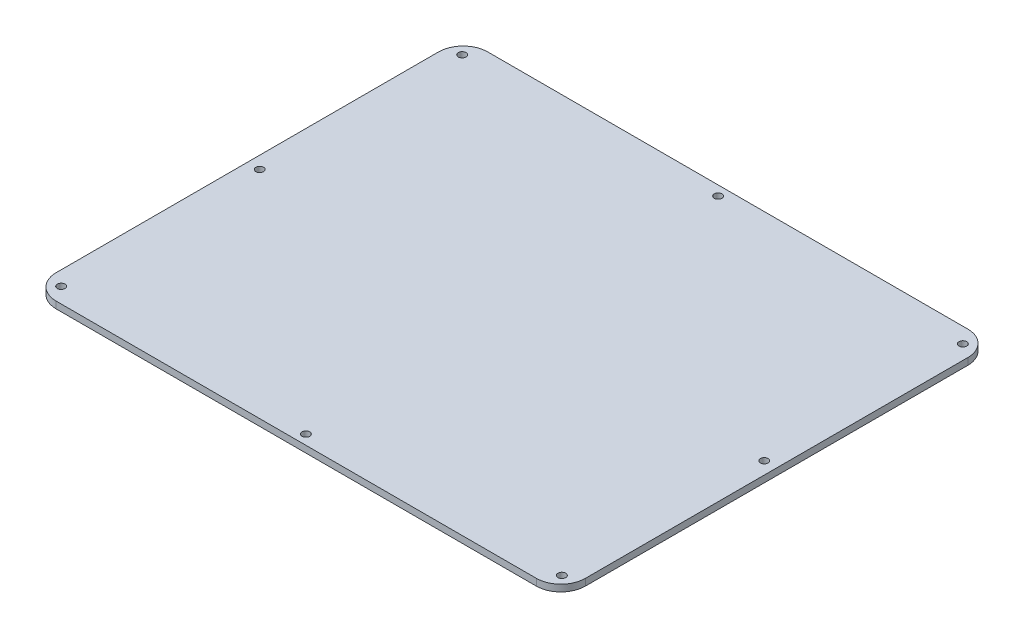
from build123d import *

# Parameters (mm, degrees)
SKETCH1_W           = 273.5
SKETCH1_H           = 223
BOSS_EXTRUDE1_DEPTH = 3.5
FILLET1_R           = 12.7
SKETCH2_R           = 2
CUT_EXTRUDE1_DEPTH  = 3.5


with BuildPart() as part:
    # Sketch1 → Boss-Extrude1 (new body)
    with BuildSketch(Plane(origin=(0, 0, 0), x_dir=(1, 0, 0), z_dir=(0, 1, 0))):
        with Locations((-19.268652803, -12.454205426)):
            Rectangle(SKETCH1_W, SKETCH1_H)
    extrude(amount=BOSS_EXTRUDE1_DEPTH)

    # Fillet1
    fillet1_edges = [part.edges().sort_by_distance(p)[0] for p in [
        (-156.018652803, 1.75, -99.045794574),
        (117.481347197, 1.75, -99.045794574),
        (117.481347197, 1.75, 123.954205426),
        (-156.018652803, 1.75, 123.954205426),
    ]]
    fillet(fillet1_edges, radius=FILLET1_R)

    # Sketch2 → Cut-Extrude1 (cut)
    with BuildSketch(Plane(origin=(0, 3.5, 0), x_dir=(1, 0, 0), z_dir=(0, 1, 0))):
        with Locations((-19.268652803, 94.045794574)):
            Circle(SKETCH2_R)
        with Locations((-148.618652803, 91.145794574)):
            Circle(SKETCH2_R)
        with Locations((110.081347197, 91.145794574)):
            Circle(SKETCH2_R)
        with Locations((110.081347197, -116.054205426)):
            Circle(SKETCH2_R)
        with Locations((-148.618652803, -116.054205426)):
            Circle(SKETCH2_R)
        with Locations((-19.268652803, -118.954205426)):
            Circle(SKETCH2_R)
        with Locations((111.081347197, -12.454205426)):
            Circle(SKETCH2_R)
        with Locations((-149.618652803, -12.454205426)):
            Circle(SKETCH2_R)
    extrude(amount=-CUT_EXTRUDE1_DEPTH, mode=Mode.SUBTRACT)


solid = part.part
